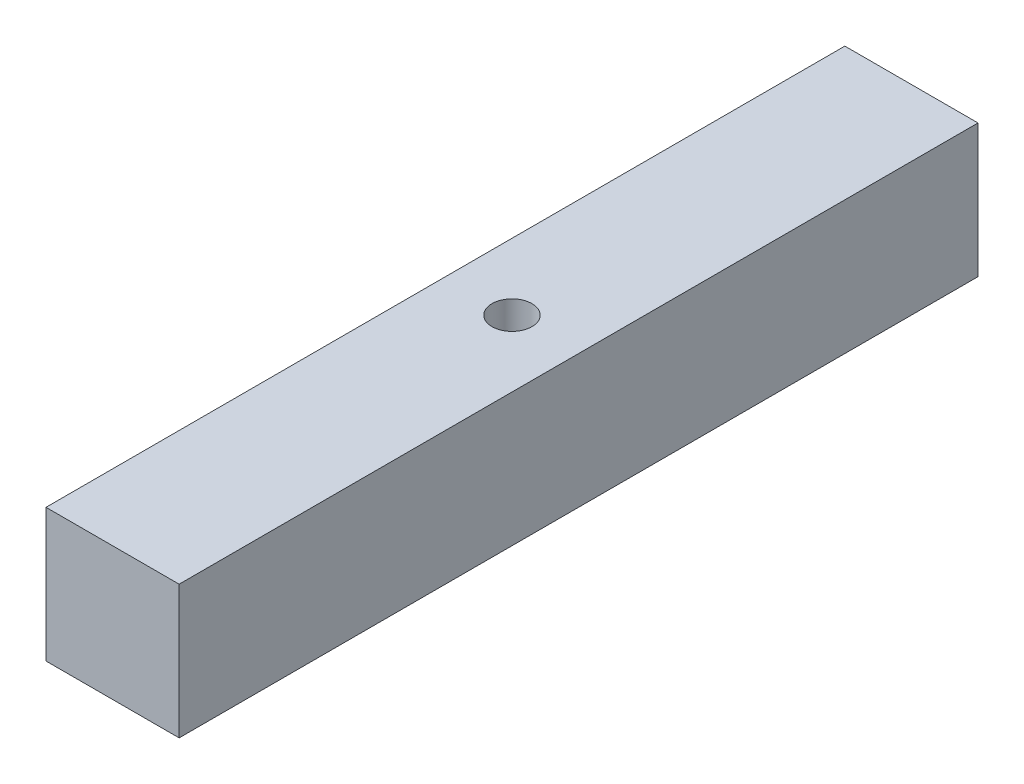
from build123d import *

# Parameters (mm, degrees)
SKETCH1_W           = 50
SKETCH1_H           = 50
BOSS_EXTRUDE1_DEPTH = 300
SKETCH2_R           = 7.5
CUT_EXTRUDE1_DEPTH  = 15


with BuildPart() as part:
    # Sketch1 → Boss-Extrude1 (new body)
    with BuildSketch(Plane.XY):
        with Locations((475, -275)):
            Rectangle(SKETCH1_W, SKETCH1_H)
    extrude(amount=BOSS_EXTRUDE1_DEPTH)

    # Sketch2 → Cut-Extrude1 (cut)
    with BuildSketch(Plane(origin=(0, -250, 0), x_dir=(1, 0, 0), z_dir=(0, 1, 0))):
        with Locations((475, -150)):
            Circle(SKETCH2_R)
    extrude(amount=-CUT_EXTRUDE1_DEPTH, mode=Mode.SUBTRACT)


solid = part.part
